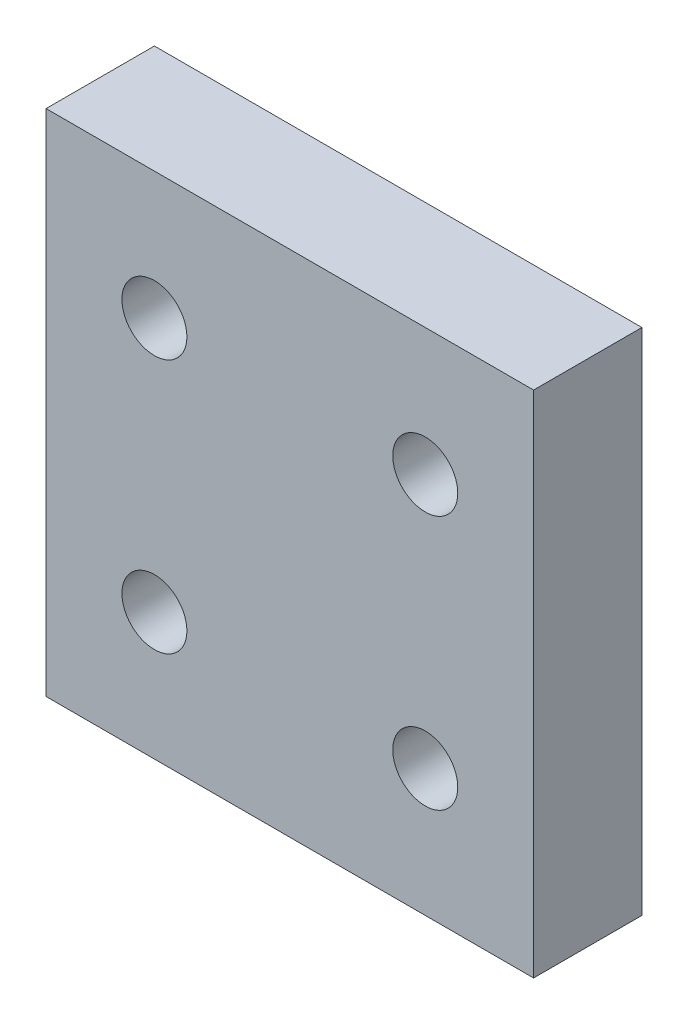
from build123d import *

# Parameters (mm, degrees)
ESQUISSE1_W        = 18
ESQUISSE1_H        = 18.8
ESQUISSE1_R        = 1.2
BOSS_EXTRU_1_DEPTH = 4


with BuildPart() as part:
    # Esquisse1 → Boss.-Extru.1 (new body)
    with BuildSketch(Plane.XY):
        Rectangle(ESQUISSE1_W, ESQUISSE1_H)
        with Locations((-5, 4.7)):
            Circle(ESQUISSE1_R, mode=Mode.SUBTRACT)
        with Locations((5, 4.7)):
            Circle(ESQUISSE1_R, mode=Mode.SUBTRACT)
        with Locations((5, -4.7)):
            Circle(ESQUISSE1_R, mode=Mode.SUBTRACT)
        with Locations((-5, -4.7)):
            Circle(ESQUISSE1_R, mode=Mode.SUBTRACT)
    extrude(amount=BOSS_EXTRU_1_DEPTH)


solid = part.part
